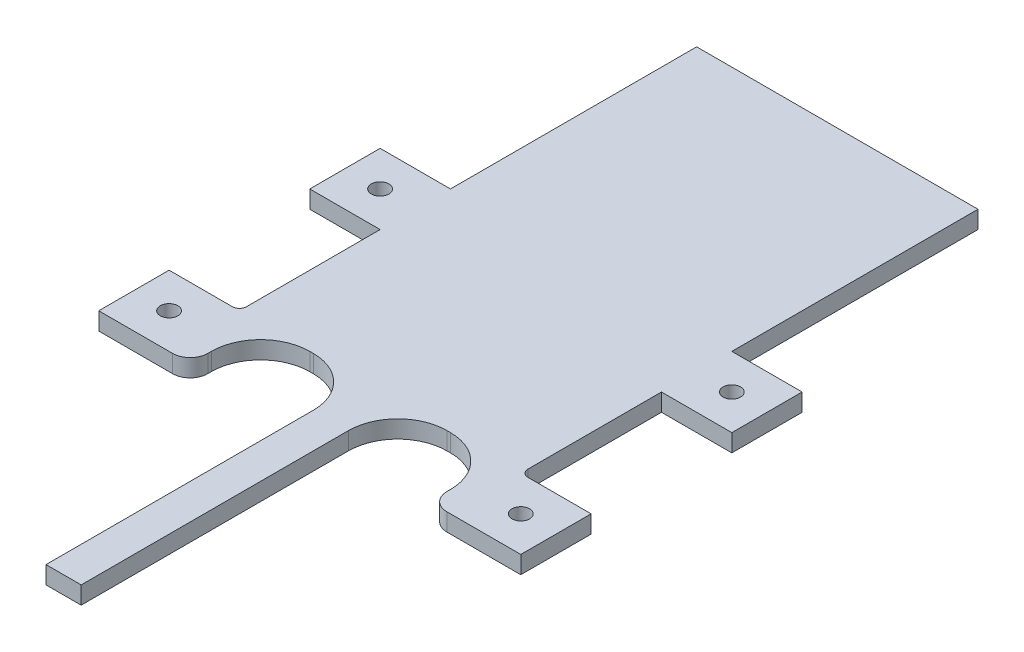
from build123d import *

# Parameters (mm, degrees)
SKETCH1_W           = 50.8
SKETCH1_H           = 76.2
BOSS_EXTRUDE1_DEPTH = 3.175
SKETCH2_W           = 18.415
SKETCH2_H           = 63.5
CUT_EXTRUDE1_DEPTH  = 3.175
SKETCH3_W           = 12.7
SKETCH3_H           = 12.7
SKETCH3_R           = 1.5875
BOSS_EXTRUDE2_DEPTH = 3.175
SKETCH7_W           = 50.8
SKETCH7_H           = 12.7
BOSS_EXTRUDE3_DEPTH = 3.175
SKETCH8_W           = 50.8
SKETCH8_H           = 57.15
BOSS_EXTRUDE4_DEPTH = 3.175
LPATTERN1_COUNT     = 2
LPATTERN1_PITCH     = 38.1
FILLET1_R           = 8.89
SKETCH9_W           = 6.35
SKETCH9_H           = 6.35
CUT_EXTRUDE2_DEPTH  = 3.175
SKETCH10_W          = 3.81
SKETCH10_H          = 50.8
CUT_EXTRUDE3_DEPTH  = 3.175
FILLET2_R           = 3.175
FILLET3_R           = 1.27


with BuildPart() as part:
    # Sketch1 → Boss-Extrude1 (new body)
    with BuildSketch(Plane(origin=(0, 0, 0), x_dir=(1, 0, 0), z_dir=(0, 1, 0))):
        with Locations((25.4, 38.1)):
            Rectangle(SKETCH1_W, SKETCH1_H)
    extrude(amount=BOSS_EXTRUDE1_DEPTH)

    # Sketch2 → Cut-Extrude1 (cut)
    with BuildSketch(Plane(origin=(0, 3.175, 0), x_dir=(1, 0, 0), z_dir=(0, 1, 0))):
        with Locations((13.0175, 31.75)):
            Rectangle(SKETCH2_W, SKETCH2_H)
        with Locations((37.7825, 31.75)):
            Rectangle(SKETCH2_W, SKETCH2_H)
    extrude(amount=-CUT_EXTRUDE1_DEPTH, mode=Mode.SUBTRACT)

    # Sketch3 → Boss-Extrude2 (add)
    with BuildSketch(Plane(origin=(0, 3.175, 0), x_dir=(1, 0, 0), z_dir=(0, 1, 0))):
        with Locations((-6.35, 57.15)):
            Rectangle(SKETCH3_W, SKETCH3_H)
        with Locations((-6.35, 57.15)):
            Circle(SKETCH3_R, mode=Mode.SUBTRACT)
        with Locations((57.15, 57.15)):
            Rectangle(SKETCH3_W, SKETCH3_H)
        with Locations((57.15, 57.15)):
            Circle(SKETCH3_R, mode=Mode.SUBTRACT)
    boss_extrude2 = extrude(amount=-BOSS_EXTRUDE2_DEPTH)

    # Sketch7 → Boss-Extrude3 (add)
    with BuildSketch(Plane(origin=(0, 3.175, 0), x_dir=(1, 0, 0), z_dir=(0, 1, 0))):
        with Locations((25.4, 82.55)):
            Rectangle(SKETCH7_W, SKETCH7_H)
    extrude(amount=-BOSS_EXTRUDE3_DEPTH)

    # Sketch8 → Boss-Extrude4 (add)
    with BuildSketch(Plane.XZ):
        with Locations((25.4, -117.475)):
            Rectangle(SKETCH8_W, SKETCH8_H)
    extrude(amount=-BOSS_EXTRUDE4_DEPTH)

    # LPattern1: Boss-Extrude2 ×2
    with Locations(*[(0, 0, -i * LPATTERN1_PITCH) for i in range(1, LPATTERN1_COUNT)]):
        add(boss_extrude2)

    # Fillet1
    fillet1_edges = [part.edges().sort_by_distance(p)[0] for p in [
        (3.81, 1.5875, -63.5),
        (22.225, 1.5875, -63.5),
        (28.575, 1.5875, -63.5),
        (46.99, 1.5875, -63.5),
    ]]
    fillet(fillet1_edges, radius=FILLET1_R)

    # Sketch9 → Cut-Extrude2 (cut)
    with BuildSketch(Plane(origin=(0, 3.175, 0), x_dir=(1, 0, 0), z_dir=(0, 1, 0))):
        with Locations((25.4, 3.175)):
            Rectangle(SKETCH9_W, SKETCH9_H)
    extrude(amount=-CUT_EXTRUDE2_DEPTH, mode=Mode.SUBTRACT)

    # Sketch10 → Cut-Extrude3 (cut)
    with BuildSketch(Plane(origin=(0, 3.175, 0), x_dir=(1, 0, 0), z_dir=(0, 1, 0))):
        with Locations((1.905, 25.4)):
            Rectangle(SKETCH10_W, SKETCH10_H)
        with Locations((48.895, 25.4)):
            Rectangle(SKETCH10_W, SKETCH10_H)
    extrude(amount=-CUT_EXTRUDE3_DEPTH, mode=Mode.SUBTRACT)

    # Fillet2
    fillet2_edges = [part.edges().sort_by_distance(p)[0] for p in [
        (3.81, 1.5875, -50.8),
        (46.99, 1.5875, -50.8),
    ]]
    fillet(fillet2_edges, radius=FILLET2_R)

    # Fillet3
    fillet3_edges = [part.edges().sort_by_distance(p)[0] for p in [
        (0, 1.5875, -63.5),
        (50.8, 1.5875, -63.5),
    ]]
    fillet(fillet3_edges, radius=FILLET3_R)


solid = part.part
